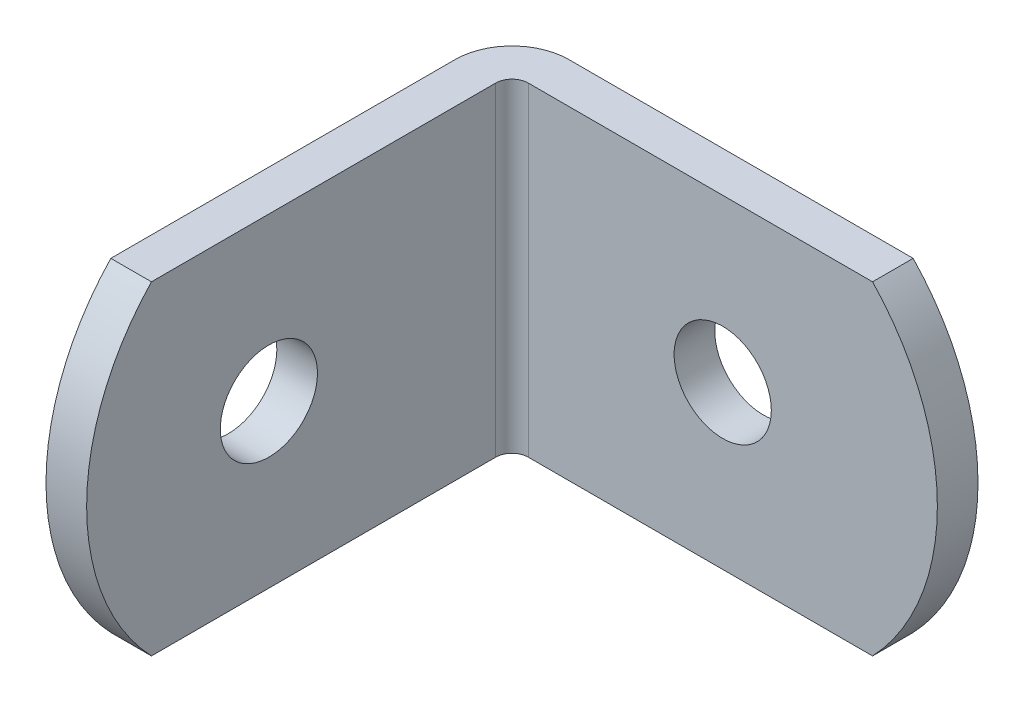
from build123d import *

# Parameters (mm, degrees)
EXTRUDE_THIN1_DEPTH     = 8.001
CUT_EXTRUDE1_DEPTH      = 22.0058
CUT_EXTRUDE1_DEPTH_BACK = 3.0066
SKETCH7_R               = 2.4
CUT_EXTRUDE3_DEPTH      = 3.0066
CUT_EXTRUDE2_DEPTH      = 22.0058
CUT_EXTRUDE2_DEPTH_BACK = 3.0066
SKETCH8_R               = 2.4
CUT_EXTRUDE4_DEPTH      = 3.0066


with BuildPart() as part:
    # Sketch4 → Extrude-Thin1 (new body, symmetric)
    with BuildSketch(Plane(origin=(0, 0, 0), x_dir=(1, 0, 0), z_dir=(0, 1, 0))):
        with BuildLine():
            Line((23.0124, 0), (2.80924, 0))
            ThreePointArc((2.80924, 0), (0.822807346, -0.822807346), (0, -2.80924))
            Line((0, -2.80924), (0, -23.0124))
            Line((0, -23.0124), (2.0066, -23.0124))
            Line((2.0066, -23.0124), (2.0066, -2.80924))
            ThreePointArc((2.0066, -2.80924), (2.241687813, -2.241687813), (2.80924, -2.0066))
            Line((2.80924, -2.0066), (23.0124, -2.0066))
            Line((23.0124, -2.0066), (23.0124, 0))
        make_face()
    extrude(amount=EXTRUDE_THIN1_DEPTH, both=True)

    # Sketch5 → Cut-Extrude1 (cut, two sides)
    with BuildSketch(Plane(origin=(2.0066, 0, 0), x_dir=(0, 0, -1), z_dir=(1, 0, 0))) as cut_extrude1_sk:
        with BuildLine():
            Line((22.211753172, 52.125940831), (-19.812, 8.001))
            ThreePointArc((-19.812, 8.001), (-23.0124, 0), (-19.812, -8.001))
            Line((-19.812, -8.001), (22.211753172, -52.125940831))
            Line((22.211753172, -52.125940831), (-99.657131027, -52.125940831))
            Line((-99.657131027, -52.125940831), (-99.657131027, 52.125940831))
            Line((-99.657131027, 52.125940831), (22.211753172, 52.125940831))
        make_face()
    extrude(amount=CUT_EXTRUDE1_DEPTH, mode=Mode.SUBTRACT)
    extrude(cut_extrude1_sk.sketch, amount=-CUT_EXTRUDE1_DEPTH_BACK, mode=Mode.SUBTRACT)

    # Sketch7 → Cut-Extrude3 (cut, through all)
    with BuildSketch(Plane(origin=(2.0066, 0, 0), x_dir=(0, 0, -1), z_dir=(1, 0, 0))):
        with Locations((-14.0124, 0)):
            Circle(SKETCH7_R)
    extrude(amount=-CUT_EXTRUDE3_DEPTH, mode=Mode.SUBTRACT)

    # Sketch6 → Cut-Extrude2 (cut, two sides)
    with BuildSketch(Plane.XY.offset(2.0066)) as cut_extrude2_sk:
        with BuildLine():
            Line((-22.211753172, -52.125940831), (19.812, -8.001))
            ThreePointArc((19.812, -8.001), (23.0124, 0), (19.812, 8.001))
            Line((19.812, 8.001), (-22.211753172, 52.125940831))
            Line((-22.211753172, 52.125940831), (99.657131027, 52.125940831))
            Line((99.657131027, 52.125940831), (99.657131027, -52.125940831))
            Line((99.657131027, -52.125940831), (-22.211753172, -52.125940831))
        make_face()
    extrude(amount=CUT_EXTRUDE2_DEPTH, mode=Mode.SUBTRACT)
    extrude(cut_extrude2_sk.sketch, amount=-CUT_EXTRUDE2_DEPTH_BACK, mode=Mode.SUBTRACT)

    # Sketch8 → Cut-Extrude4 (cut, through all)
    with BuildSketch(Plane.XY.offset(2.0066)):
        with Locations((12.4124, 0)):
            Circle(SKETCH8_R)
    extrude(amount=-CUT_EXTRUDE4_DEPTH, mode=Mode.SUBTRACT)


solid = part.part
